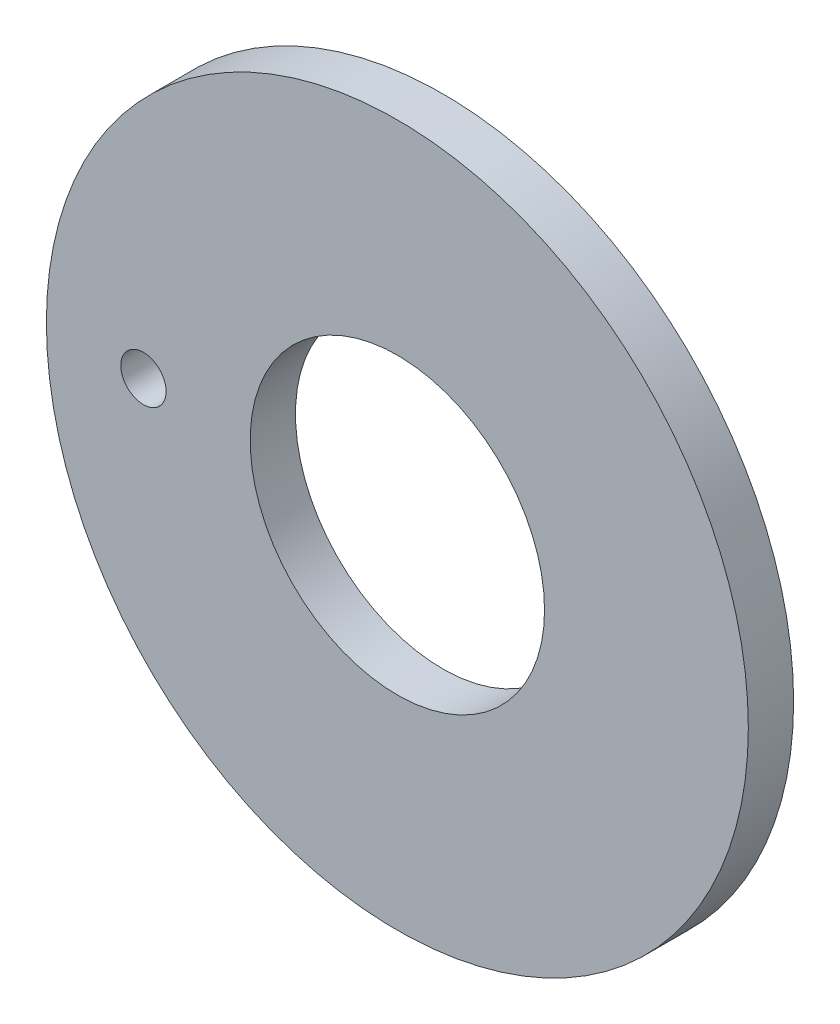
from build123d import *

# Parameters (mm, degrees)
SKETCH1_R           = 49.2125
SKETCH1_R_2         = 3.175
SKETCH1_R_3         = 20.6375
BOSS_EXTRUDE1_DEPTH = 6.35


with BuildPart() as part:
    # Sketch1 → Boss-Extrude1 (new body)
    with BuildSketch(Plane.XY):
        Circle(SKETCH1_R)
        with Locations((-35.601789015, 0)):
            Circle(SKETCH1_R_2, mode=Mode.SUBTRACT)
        Circle(SKETCH1_R_3, mode=Mode.SUBTRACT)
    extrude(amount=BOSS_EXTRUDE1_DEPTH)


solid = part.part
